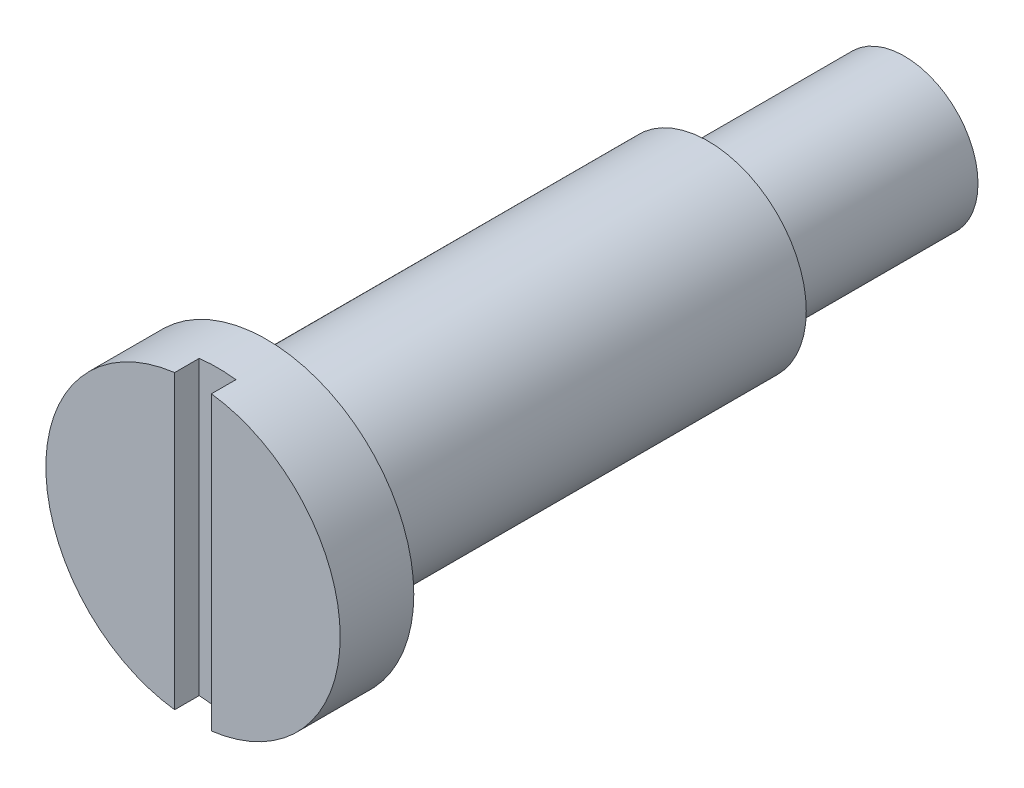
from build123d import *

# Parameters (mm, degrees)
SKETCH_3_W          = 1.5
SKETCH_3_H          = 12
CUT_EXTRUDE_1_DEPTH = 1


with BuildPart() as part:
    # 草图2 → 旋转1 (revolve)
    with BuildSketch(Plane(origin=(0, 0, 0), x_dir=(0, 0, -1), z_dir=(1, 0, 0))):
        Polygon((0, 0), (0, 6), (3, 6), (3, 4), (21, 4), (21, 3), (29, 3), (29, 0), align=None)
    revolve(axis=Axis((0, 0, 0), (0, 0, -1)))

    # 草图3 → 切除-拉伸1 (cut)
    with BuildSketch(Plane.XY):
        Rectangle(SKETCH_3_W, SKETCH_3_H)
    extrude(amount=-CUT_EXTRUDE_1_DEPTH, mode=Mode.SUBTRACT)


solid = part.part
